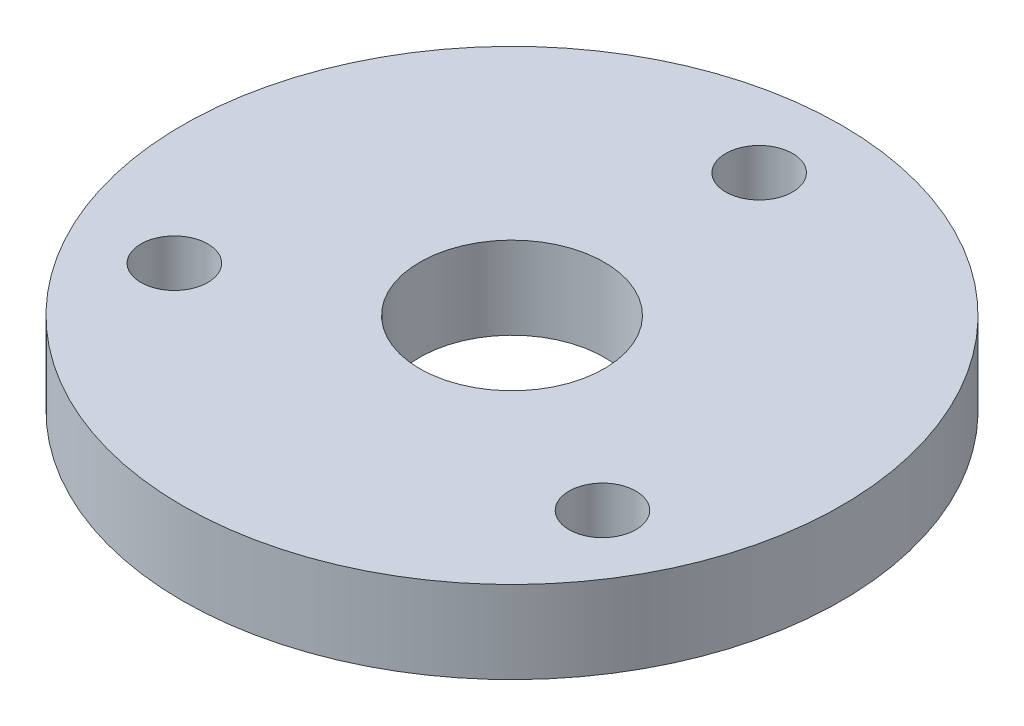
from build123d import *

# Parameters (mm, degrees)
SKETCH1_R           = 100
SKETCH1_R_2         = 28
SKETCH1_R_3         = 10.15
BOSS_EXTRUDE1_DEPTH = 12.5


with BuildPart() as part:
    # Sketch1 → Boss-Extrude1 (new body, symmetric)
    with BuildSketch(Plane(origin=(0, 0, 0), x_dir=(1, 0, 0), z_dir=(0, 1, 0))):
        Circle(SKETCH1_R)
        Circle(SKETCH1_R_2, mode=Mode.SUBTRACT)
        with Locations((0, 75)):
            Circle(SKETCH1_R_3, mode=Mode.SUBTRACT)
        with Locations((64.951905284, -37.5)):
            Circle(SKETCH1_R_3, mode=Mode.SUBTRACT)
        with Locations((-64.951905284, -37.5)):
            Circle(SKETCH1_R_3, mode=Mode.SUBTRACT)
    extrude(amount=BOSS_EXTRUDE1_DEPTH, both=True)


solid = part.part
